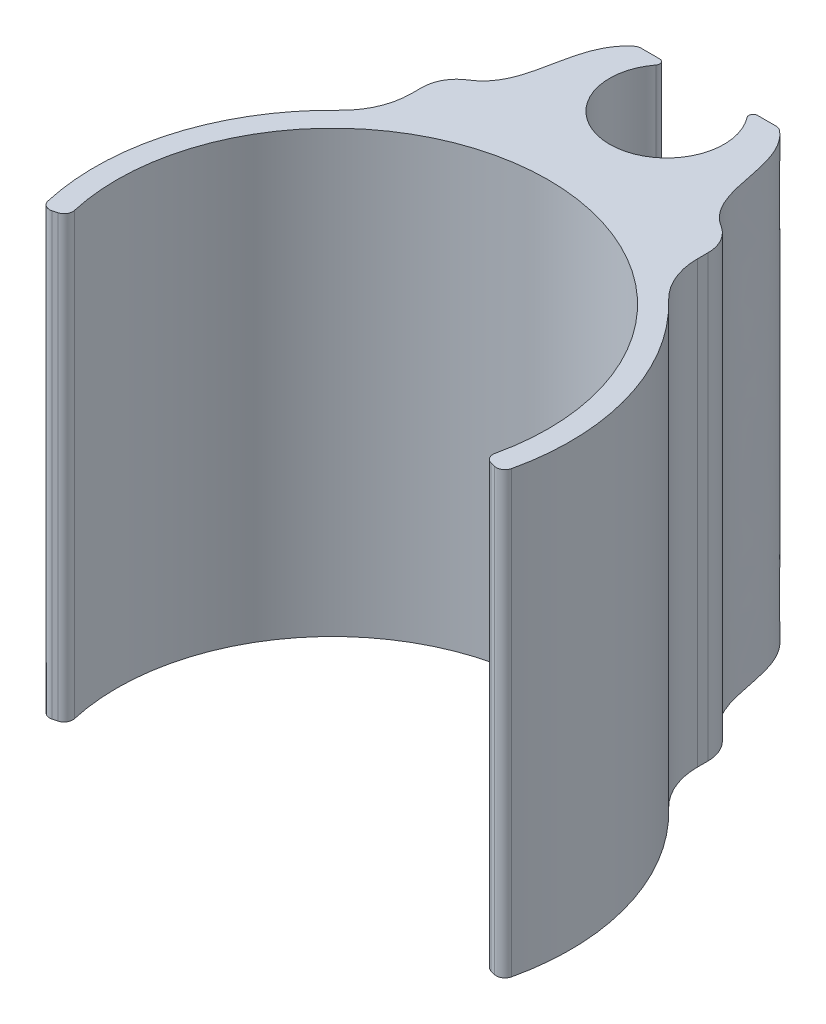
from build123d import *

# Parameters (mm, degrees)
BOSS_EXTRUDE1_DEPTH = 25.4
SKETCH2_R           = 3.302
CUT_EXTRUDE1_DEPTH  = 25.4
FILLET1_R           = 0.508
FILLET2_R           = 0.254
FILLET3_R           = 2
FILLET4_R           = 4
FILLET5_R           = 0.5


with BuildPart() as part:
    # Sketch1 → Boss-Extrude1 (new body)
    with BuildSketch(Plane(origin=(0, 0, 0), x_dir=(1, 0, 0), z_dir=(0, 1, 0))):
        with BuildLine():
            Line((-13.248638633, -3.549962023), (-12.021912834, -3.221261835))
            ThreePointArc((-12.021912834, -3.221261835), (0, 12.446), (12.021912834, -3.221261835))
            Line((12.021912834, -3.221261835), (13.248638633, -3.549962023))
            ThreePointArc((13.248638633, -3.549962023), (12.968835743, 4.465193777), (8.255, 10.953703985))
            Line((8.255, 10.953703985), (8.255, 14.716))
            Line((8.255, 14.716), (8.255, 21.701))
            Line((8.255, 21.701), (-8.255, 21.701))
            Line((-8.255, 21.701), (-8.255, 14.716))
            Line((-8.255, 14.716), (-8.255, 10.953703985))
            ThreePointArc((-8.255, 10.953703985), (-12.968835743, 4.465193777), (-13.248638633, -3.549962023))
        make_face()
    extrude(amount=BOSS_EXTRUDE1_DEPTH)

    # Sketch2 → Cut-Extrude1 (cut)
    with BuildSketch(Plane(origin=(0, 25.4, 0), x_dir=(1, 0, 0), z_dir=(0, 1, 0))):
        with Locations((0, 19.28817272)):
            Circle(SKETCH2_R)
        with BuildLine():
            Line((-8.255, 21.701), (-8.255, 14.716))
            add(Edge.make_bspline(
                [(-8.255, 14.716), (-4.739338783, 15.636189596), (-6.519245554, 19.893117267), (-4.063143766, 21.701)],
                knots=[0, 0, 0, 0, 1, 1, 1, 1], degree=3))
            Line((-4.063143766, 21.701), (-8.255, 21.701))
        make_face()
        with BuildLine():
            Line((8.255, 21.701), (8.255, 14.716))
            add(Edge.make_bspline(
                [(8.255, 14.716), (4.739338783, 15.636189596), (6.519245554, 19.893117267), (4.063143766, 21.701)],
                knots=[0, 0, 0, 0, 1, 1, 1, 1], degree=3))
            Line((4.063143766, 21.701), (8.255, 21.701))
        make_face()
    extrude(amount=-CUT_EXTRUDE1_DEPTH, mode=Mode.SUBTRACT)

    # Fillet1
    fillet1_edges = [part.edges().sort_by_distance(p)[0] for p in [
        (-4.063143766, 12.7, -21.701),
        (4.063143766, 12.7, -21.701),
    ]]
    fillet(fillet1_edges, radius=FILLET1_R)

    # Fillet2
    fillet2_edges = [part.edges().sort_by_distance(p)[0] for p in [
        (2.254211285, 12.7, -21.701),
        (-2.254211285, 12.7, -21.701),
    ]]
    fillet(fillet2_edges, radius=FILLET2_R)

    # Fillet3
    fillet3_edges = [part.edges().sort_by_distance(p)[0] for p in [
        (-8.255, 12.7, -14.716),
        (8.255, 12.7, -14.716),
    ]]
    fillet(fillet3_edges, radius=FILLET3_R)

    # Fillet4
    fillet4_edges = [part.edges().sort_by_distance(p)[0] for p in [
        (-8.255, 12.7, -10.953703985),
        (8.255, 12.7, -10.953703985),
    ]]
    fillet(fillet4_edges, radius=FILLET4_R)

    # Fillet5
    fillet5_edges = [part.edges().sort_by_distance(p)[0] for p in [
        (13.248638633, 12.7, 3.549962023),
        (12.021912834, 12.7, 3.221261835),
        (-12.021912834, 12.7, 3.221261835),
        (-13.248638633, 12.7, 3.549962023),
    ]]
    fillet(fillet5_edges, radius=FILLET5_R)


solid = part.part
